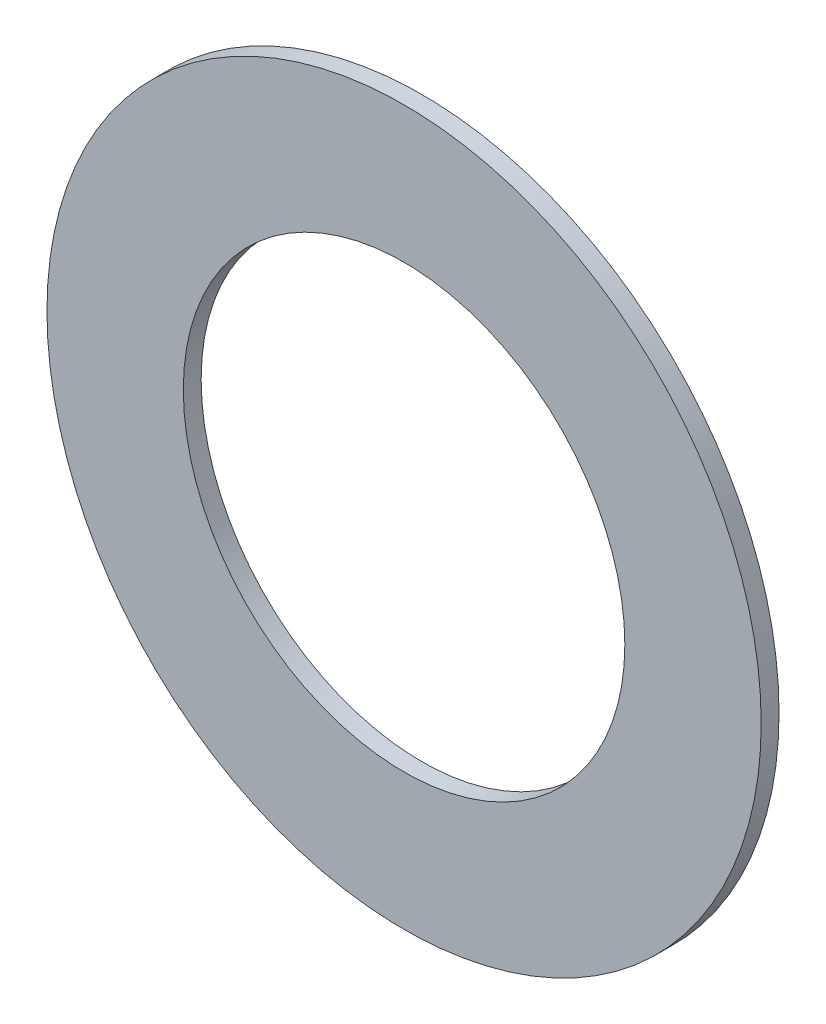
from build123d import *

# Parameters (mm, degrees)
SKETCH1_R           = 63.5
SKETCH1_R_2         = 39.2557
BOSS_EXTRUDE1_DEPTH = 3.175


with BuildPart() as part:
    # Sketch1 → Boss-Extrude1 (new body)
    with BuildSketch(Plane.XY):
        Circle(SKETCH1_R)
        Circle(SKETCH1_R_2, mode=Mode.SUBTRACT)
    extrude(amount=BOSS_EXTRUDE1_DEPTH)


solid = part.part
